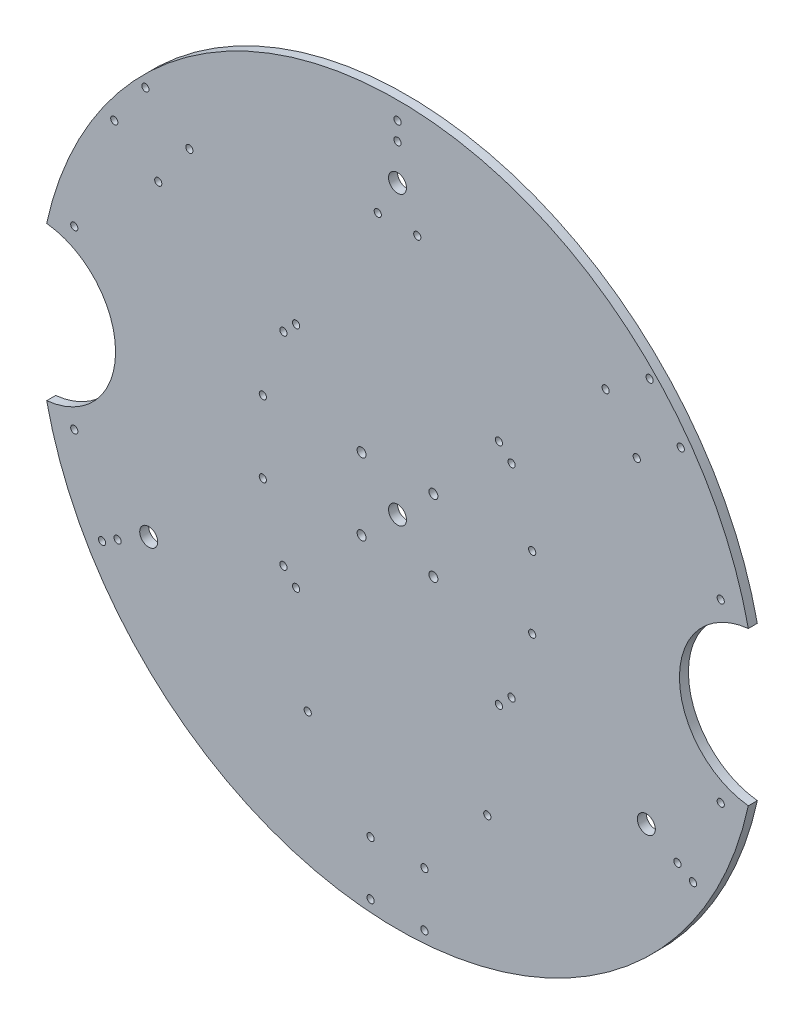
from build123d import *

# Parameters (mm, degrees)
SKETCH1_R           = 200
BOSS_EXTRUDE1_DEPTH = 5
SKETCH3_R           = 2
CUT_EXTRUDE1_DEPTH  = 5
CIRPATTERN1_COUNT   = 3
CUT_EXTRUDE2_REACH  = 7
SKETCH4_R           = 43
CUT_EXTRUDE3_REACH  = 7
SKETCH5_R           = 2
CUT_EXTRUDE4_REACH  = 7
SKETCH6_R           = 2.5
SKETCH6_R_2         = 5
CUT_EXTRUDE5_REACH  = 7
SKETCH7_R           = 2
CUT_EXTRUDE6_REACH  = 7
SKETCH8_R           = 2
CUT_EXTRUDE7_REACH  = 7
SKETCH9_R           = 2
CUT_EXTRUDE8_REACH  = 7
SKETCH11_R          = 2
CUT_EXTRUDE9_REACH  = 7
SKETCH12_R          = 2
CUT_EXTRUDE10_REACH = 7
SKETCH10_R          = 5


with BuildPart() as part:
    # Sketch1 → Boss-Extrude1 (new body)
    with BuildSketch(Plane.XY):
        Circle(SKETCH1_R)
    extrude(amount=BOSS_EXTRUDE1_DEPTH)

    # Sketch3 → Cut-Extrude1 (cut)
    with BuildSketch(Plane.XY.offset(5)):
        with Locations((0, 190)):
            Circle(SKETCH3_R)
        with Locations((0, 180)):
            Circle(SKETCH3_R)
    cut_extrude1 = extrude(amount=-CUT_EXTRUDE1_DEPTH, mode=Mode.SUBTRACT)

    # CirPattern1: Cut-Extrude1 ×3 about axis
    cirpattern1_axis = Axis((0, 0, 0), (0, 0, 1))
    for i in range(1, CIRPATTERN1_COUNT):
        add(cut_extrude1.rotate(cirpattern1_axis, i * 360 / CIRPATTERN1_COUNT), mode=Mode.SUBTRACT)

    # Sketch4 → Cut-Extrude2 (cut, up to next)
    with BuildSketch(Plane.XY.offset(5), mode=Mode.PRIVATE) as cut_extrude2_sk1:
        with Locations((-200, 0)):
            Circle(SKETCH4_R)
    cut_extrude2_tool1 = extrude(cut_extrude2_sk1.sketch, amount=-CUT_EXTRUDE2_REACH, mode=Mode.PRIVATE) & part.part
    add(cut_extrude2_tool1.solids().sort_by_distance((-200, 0, 5))[0], mode=Mode.SUBTRACT)
    # Sketch4 → Cut-Extrude2 (cut, up to next)
    with BuildSketch(Plane.XY.offset(5), mode=Mode.PRIVATE) as cut_extrude2_sk2:
        with Locations((200, 0)):
            Circle(SKETCH4_R)
    cut_extrude2_tool2 = extrude(cut_extrude2_sk2.sketch, amount=-CUT_EXTRUDE2_REACH, mode=Mode.PRIVATE) & part.part
    add(cut_extrude2_tool2.solids().sort_by_distance((200, 0, 5))[0], mode=Mode.SUBTRACT)

    # Sketch5 → Cut-Extrude3 (cut, up to next)
    with BuildSketch(Plane.XY.offset(5), mode=Mode.PRIVATE) as cut_extrude3_sk1:
        with Locations((180, 49)):
            Circle(SKETCH5_R)
    cut_extrude3_tool1 = extrude(cut_extrude3_sk1.sketch, amount=-CUT_EXTRUDE3_REACH, mode=Mode.PRIVATE) & part.part
    add(cut_extrude3_tool1.solids().sort_by_distance((180, 49, 5))[0], mode=Mode.SUBTRACT)
    # Sketch5 → Cut-Extrude3 (cut, up to next)
    with BuildSketch(Plane.XY.offset(5), mode=Mode.PRIVATE) as cut_extrude3_sk2:
        with Locations((180, -49)):
            Circle(SKETCH5_R)
    cut_extrude3_tool2 = extrude(cut_extrude3_sk2.sketch, amount=-CUT_EXTRUDE3_REACH, mode=Mode.PRIVATE) & part.part
    add(cut_extrude3_tool2.solids().sort_by_distance((180, -49, 5))[0], mode=Mode.SUBTRACT)
    # Sketch5 → Cut-Extrude3 (cut, up to next)
    with BuildSketch(Plane.XY.offset(5), mode=Mode.PRIVATE) as cut_extrude3_sk3:
        with Locations((-180, -49)):
            Circle(SKETCH5_R)
    cut_extrude3_tool3 = extrude(cut_extrude3_sk3.sketch, amount=-CUT_EXTRUDE3_REACH, mode=Mode.PRIVATE) & part.part
    add(cut_extrude3_tool3.solids().sort_by_distance((-180, -49, 5))[0], mode=Mode.SUBTRACT)
    # Sketch5 → Cut-Extrude3 (cut, up to next)
    with BuildSketch(Plane.XY.offset(5), mode=Mode.PRIVATE) as cut_extrude3_sk4:
        with Locations((-180, 49)):
            Circle(SKETCH5_R)
    cut_extrude3_tool4 = extrude(cut_extrude3_sk4.sketch, amount=-CUT_EXTRUDE3_REACH, mode=Mode.PRIVATE) & part.part
    add(cut_extrude3_tool4.solids().sort_by_distance((-180, 49, 5))[0], mode=Mode.SUBTRACT)

    # Sketch6 → Cut-Extrude4 (cut, up to next)
    with BuildSketch(Plane.XY.offset(5), mode=Mode.PRIVATE) as cut_extrude4_sk1:
        with Locations((-20, -20)):
            Circle(SKETCH6_R)
    cut_extrude4_tool1 = extrude(cut_extrude4_sk1.sketch, amount=-CUT_EXTRUDE4_REACH, mode=Mode.PRIVATE) & part.part
    add(cut_extrude4_tool1.solids().sort_by_distance((-20, -20, 5))[0], mode=Mode.SUBTRACT)
    # Sketch6 → Cut-Extrude4 (cut, up to next)
    with BuildSketch(Plane.XY.offset(5), mode=Mode.PRIVATE) as cut_extrude4_sk2:
        with Locations((-20, 20)):
            Circle(SKETCH6_R)
    cut_extrude4_tool2 = extrude(cut_extrude4_sk2.sketch, amount=-CUT_EXTRUDE4_REACH, mode=Mode.PRIVATE) & part.part
    add(cut_extrude4_tool2.solids().sort_by_distance((-20, 20, 5))[0], mode=Mode.SUBTRACT)
    # Sketch6 → Cut-Extrude4 (cut, up to next)
    with BuildSketch(Plane.XY.offset(5), mode=Mode.PRIVATE) as cut_extrude4_sk3:
        Circle(SKETCH6_R_2)
    cut_extrude4_tool3 = extrude(cut_extrude4_sk3.sketch, amount=-CUT_EXTRUDE4_REACH, mode=Mode.PRIVATE) & part.part
    add(cut_extrude4_tool3.solids().sort_by_distance((0, 0, 5))[0], mode=Mode.SUBTRACT)
    # Sketch6 → Cut-Extrude4 (cut, up to next)
    with BuildSketch(Plane.XY.offset(5), mode=Mode.PRIVATE) as cut_extrude4_sk4:
        with Locations((20, -20)):
            Circle(SKETCH6_R)
    cut_extrude4_tool4 = extrude(cut_extrude4_sk4.sketch, amount=-CUT_EXTRUDE4_REACH, mode=Mode.PRIVATE) & part.part
    add(cut_extrude4_tool4.solids().sort_by_distance((20, -20, 5))[0], mode=Mode.SUBTRACT)
    # Sketch6 → Cut-Extrude4 (cut, up to next)
    with BuildSketch(Plane.XY.offset(5), mode=Mode.PRIVATE) as cut_extrude4_sk5:
        with Locations((20, 20)):
            Circle(SKETCH6_R)
    cut_extrude4_tool5 = extrude(cut_extrude4_sk5.sketch, amount=-CUT_EXTRUDE4_REACH, mode=Mode.PRIVATE) & part.part
    add(cut_extrude4_tool5.solids().sort_by_distance((20, 20, 5))[0], mode=Mode.SUBTRACT)

    # Sketch7 → Cut-Extrude5 (cut, up to next)
    with BuildSketch(Plane.XY.offset(5), mode=Mode.PRIVATE) as cut_extrude5_sk1:
        with Locations((-15, -193)):
            Circle(SKETCH7_R)
    cut_extrude5_tool1 = extrude(cut_extrude5_sk1.sketch, amount=-CUT_EXTRUDE5_REACH, mode=Mode.PRIVATE) & part.part
    add(cut_extrude5_tool1.solids().sort_by_distance((-15, -193, 5))[0], mode=Mode.SUBTRACT)
    # Sketch7 → Cut-Extrude5 (cut, up to next)
    with BuildSketch(Plane.XY.offset(5), mode=Mode.PRIVATE) as cut_extrude5_sk2:
        with Locations((15, -193)):
            Circle(SKETCH7_R)
    cut_extrude5_tool2 = extrude(cut_extrude5_sk2.sketch, amount=-CUT_EXTRUDE5_REACH, mode=Mode.PRIVATE) & part.part
    add(cut_extrude5_tool2.solids().sort_by_distance((15, -193, 5))[0], mode=Mode.SUBTRACT)
    # Sketch7 → Cut-Extrude5 (cut, up to next)
    with BuildSketch(Plane.XY.offset(5), mode=Mode.PRIVATE) as cut_extrude5_sk3:
        with Locations((15, -163)):
            Circle(SKETCH7_R)
    cut_extrude5_tool3 = extrude(cut_extrude5_sk3.sketch, amount=-CUT_EXTRUDE5_REACH, mode=Mode.PRIVATE) & part.part
    add(cut_extrude5_tool3.solids().sort_by_distance((15, -163, 5))[0], mode=Mode.SUBTRACT)
    # Sketch7 → Cut-Extrude5 (cut, up to next)
    with BuildSketch(Plane.XY.offset(5), mode=Mode.PRIVATE) as cut_extrude5_sk4:
        with Locations((-15, -163)):
            Circle(SKETCH7_R)
    cut_extrude5_tool4 = extrude(cut_extrude5_sk4.sketch, amount=-CUT_EXTRUDE5_REACH, mode=Mode.PRIVATE) & part.part
    add(cut_extrude5_tool4.solids().sort_by_distance((-15, -163, 5))[0], mode=Mode.SUBTRACT)
    # Sketch7 → Cut-Extrude5 (cut, up to next)
    with BuildSketch(Plane.XY.offset(5), mode=Mode.PRIVATE) as cut_extrude5_sk5:
        with Locations((133.235060167, 93.901419803)):
            Circle(SKETCH7_R)
    cut_extrude5_tool5 = extrude(cut_extrude5_sk5.sketch, amount=-CUT_EXTRUDE5_REACH, mode=Mode.PRIVATE) & part.part
    add(cut_extrude5_tool5.solids().sort_by_distance((133.23506, 93.90142, 5))[0], mode=Mode.SUBTRACT)
    # Sketch7 → Cut-Extrude5 (cut, up to next)
    with BuildSketch(Plane.XY.offset(5), mode=Mode.PRIVATE) as cut_extrude5_sk6:
        with Locations((115.916428804, 118.39764416)):
            Circle(SKETCH7_R)
    cut_extrude5_tool6 = extrude(cut_extrude5_sk6.sketch, amount=-CUT_EXTRUDE5_REACH, mode=Mode.PRIVATE) & part.part
    add(cut_extrude5_tool6.solids().sort_by_distance((115.916429, 118.397644, 5))[0], mode=Mode.SUBTRACT)
    # Sketch7 → Cut-Extrude5 (cut, up to next)
    with BuildSketch(Plane.XY.offset(5), mode=Mode.PRIVATE) as cut_extrude5_sk7:
        with Locations((140.412653161, 135.716275522)):
            Circle(SKETCH7_R)
    cut_extrude5_tool7 = extrude(cut_extrude5_sk7.sketch, amount=-CUT_EXTRUDE5_REACH, mode=Mode.PRIVATE) & part.part
    add(cut_extrude5_tool7.solids().sort_by_distance((140.412653, 135.716276, 5))[0], mode=Mode.SUBTRACT)
    # Sketch7 → Cut-Extrude5 (cut, up to next)
    with BuildSketch(Plane.XY.offset(5), mode=Mode.PRIVATE) as cut_extrude5_sk8:
        with Locations((157.731284523, 111.220051166)):
            Circle(SKETCH7_R)
    cut_extrude5_tool8 = extrude(cut_extrude5_sk8.sketch, amount=-CUT_EXTRUDE5_REACH, mode=Mode.PRIVATE) & part.part
    add(cut_extrude5_tool8.solids().sort_by_distance((157.731285, 111.220051, 5))[0], mode=Mode.SUBTRACT)
    # Sketch7 → Cut-Extrude5 (cut, up to next)
    with BuildSketch(Plane.XY.offset(5), mode=Mode.PRIVATE) as cut_extrude5_sk9:
        with Locations((-157.731284523, 111.220051166)):
            Circle(SKETCH7_R)
    cut_extrude5_tool9 = extrude(cut_extrude5_sk9.sketch, amount=-CUT_EXTRUDE5_REACH, mode=Mode.PRIVATE) & part.part
    add(cut_extrude5_tool9.solids().sort_by_distance((-157.731285, 111.220051, 5))[0], mode=Mode.SUBTRACT)
    # Sketch7 → Cut-Extrude5 (cut, up to next)
    with BuildSketch(Plane.XY.offset(5), mode=Mode.PRIVATE) as cut_extrude5_sk10:
        with Locations((-133.235060167, 93.901419803)):
            Circle(SKETCH7_R)
    cut_extrude5_tool10 = extrude(cut_extrude5_sk10.sketch, amount=-CUT_EXTRUDE5_REACH, mode=Mode.PRIVATE) & part.part
    add(cut_extrude5_tool10.solids().sort_by_distance((-133.23506, 93.90142, 5))[0], mode=Mode.SUBTRACT)
    # Sketch7 → Cut-Extrude5 (cut, up to next)
    with BuildSketch(Plane.XY.offset(5), mode=Mode.PRIVATE) as cut_extrude5_sk11:
        with Locations((-115.916428804, 118.39764416)):
            Circle(SKETCH7_R)
    cut_extrude5_tool11 = extrude(cut_extrude5_sk11.sketch, amount=-CUT_EXTRUDE5_REACH, mode=Mode.PRIVATE) & part.part
    add(cut_extrude5_tool11.solids().sort_by_distance((-115.916429, 118.397644, 5))[0], mode=Mode.SUBTRACT)
    # Sketch7 → Cut-Extrude5 (cut, up to next)
    with BuildSketch(Plane.XY.offset(5), mode=Mode.PRIVATE) as cut_extrude5_sk12:
        with Locations((-140.412653161, 135.716275522)):
            Circle(SKETCH7_R)
    cut_extrude5_tool12 = extrude(cut_extrude5_sk12.sketch, amount=-CUT_EXTRUDE5_REACH, mode=Mode.PRIVATE) & part.part
    add(cut_extrude5_tool12.solids().sort_by_distance((-140.412653, 135.716276, 5))[0], mode=Mode.SUBTRACT)

    # Sketch8 → Cut-Extrude6 (cut, up to next)
    with BuildSketch(Plane.XY.offset(5), mode=Mode.PRIVATE) as cut_extrude6_sk1:
        with Locations((-11, 140)):
            Circle(SKETCH8_R)
    cut_extrude6_tool1 = extrude(cut_extrude6_sk1.sketch, amount=-CUT_EXTRUDE6_REACH, mode=Mode.PRIVATE) & part.part
    add(cut_extrude6_tool1.solids().sort_by_distance((-11, 140, 5))[0], mode=Mode.SUBTRACT)
    # Sketch8 → Cut-Extrude6 (cut, up to next)
    with BuildSketch(Plane.XY.offset(5), mode=Mode.PRIVATE) as cut_extrude6_sk2:
        with Locations((11, 140)):
            Circle(SKETCH8_R)
    cut_extrude6_tool2 = extrude(cut_extrude6_sk2.sketch, amount=-CUT_EXTRUDE6_REACH, mode=Mode.PRIVATE) & part.part
    add(cut_extrude6_tool2.solids().sort_by_distance((11, 140, 5))[0], mode=Mode.SUBTRACT)

    # Sketch9 → Cut-Extrude7 (cut, up to next)
    with BuildSketch(Plane.XY.offset(5), mode=Mode.PRIVATE) as cut_extrude7_sk1:
        with Locations((75, -20)):
            Circle(SKETCH9_R)
    cut_extrude7_tool1 = extrude(cut_extrude7_sk1.sketch, amount=-CUT_EXTRUDE7_REACH, mode=Mode.PRIVATE) & part.part
    add(cut_extrude7_tool1.solids().sort_by_distance((75, -20, 5))[0], mode=Mode.SUBTRACT)
    # Sketch9 → Cut-Extrude7 (cut, up to next)
    with BuildSketch(Plane.XY.offset(5), mode=Mode.PRIVATE) as cut_extrude7_sk2:
        with Locations((75, 20)):
            Circle(SKETCH9_R)
    cut_extrude7_tool2 = extrude(cut_extrude7_sk2.sketch, amount=-CUT_EXTRUDE7_REACH, mode=Mode.PRIVATE) & part.part
    add(cut_extrude7_tool2.solids().sort_by_distance((75, 20, 5))[0], mode=Mode.SUBTRACT)
    # Sketch9 → Cut-Extrude7 (cut, up to next)
    with BuildSketch(Plane.XY.offset(5), mode=Mode.PRIVATE) as cut_extrude7_sk3:
        with Locations((-75, -20)):
            Circle(SKETCH9_R)
    cut_extrude7_tool3 = extrude(cut_extrude7_sk3.sketch, amount=-CUT_EXTRUDE7_REACH, mode=Mode.PRIVATE) & part.part
    add(cut_extrude7_tool3.solids().sort_by_distance((-75, -20, 5))[0], mode=Mode.SUBTRACT)
    # Sketch9 → Cut-Extrude7 (cut, up to next)
    with BuildSketch(Plane.XY.offset(5), mode=Mode.PRIVATE) as cut_extrude7_sk4:
        with Locations((-75, 20)):
            Circle(SKETCH9_R)
    cut_extrude7_tool4 = extrude(cut_extrude7_sk4.sketch, amount=-CUT_EXTRUDE7_REACH, mode=Mode.PRIVATE) & part.part
    add(cut_extrude7_tool4.solids().sort_by_distance((-75, 20, 5))[0], mode=Mode.SUBTRACT)

    # Sketch11 → Cut-Extrude8 (cut, up to next)
    with BuildSketch(Plane(origin=(0, 0, 0), x_dir=(-1, 0, 0), z_dir=(0, 0, -1)), mode=Mode.PRIVATE) as cut_extrude8_sk1:
        with Locations((-50, -120)):
            Circle(SKETCH11_R)
    cut_extrude8_tool1 = extrude(cut_extrude8_sk1.sketch, amount=-CUT_EXTRUDE8_REACH, mode=Mode.PRIVATE) & part.part
    add(cut_extrude8_tool1.solids().sort_by_distance((50, -120, 0))[0], mode=Mode.SUBTRACT)
    # Sketch11 → Cut-Extrude8 (cut, up to next)
    with BuildSketch(Plane(origin=(0, 0, 0), x_dir=(-1, 0, 0), z_dir=(0, 0, -1)), mode=Mode.PRIVATE) as cut_extrude8_sk2:
        with Locations((50, -120)):
            Circle(SKETCH11_R)
    cut_extrude8_tool2 = extrude(cut_extrude8_sk2.sketch, amount=-CUT_EXTRUDE8_REACH, mode=Mode.PRIVATE) & part.part
    add(cut_extrude8_tool2.solids().sort_by_distance((-50, -120, 0))[0], mode=Mode.SUBTRACT)

    # Sketch12 → Cut-Extrude9 (cut, up to next)
    with BuildSketch(Plane(origin=(0, 0, 0), x_dir=(-1, 0, 0), z_dir=(0, 0, -1)), mode=Mode.PRIVATE) as cut_extrude9_sk1:
        with Locations((-63.535533906, -56.464466094)):
            Circle(SKETCH12_R)
    cut_extrude9_tool1 = extrude(cut_extrude9_sk1.sketch, amount=-CUT_EXTRUDE9_REACH, mode=Mode.PRIVATE) & part.part
    add(cut_extrude9_tool1.solids().sort_by_distance((63.535534, -56.464466, 0))[0], mode=Mode.SUBTRACT)
    # Sketch12 → Cut-Extrude9 (cut, up to next)
    with BuildSketch(Plane(origin=(0, 0, 0), x_dir=(-1, 0, 0), z_dir=(0, 0, -1)), mode=Mode.PRIVATE) as cut_extrude9_sk2:
        with Locations((-56.464466094, -63.535533906)):
            Circle(SKETCH12_R)
    cut_extrude9_tool2 = extrude(cut_extrude9_sk2.sketch, amount=-CUT_EXTRUDE9_REACH, mode=Mode.PRIVATE) & part.part
    add(cut_extrude9_tool2.solids().sort_by_distance((56.464466, -63.535534, 0))[0], mode=Mode.SUBTRACT)
    # Sketch12 → Cut-Extrude9 (cut, up to next)
    with BuildSketch(Plane(origin=(0, 0, 0), x_dir=(-1, 0, 0), z_dir=(0, 0, -1)), mode=Mode.PRIVATE) as cut_extrude9_sk3:
        with Locations((63.535533906, -56.464466094)):
            Circle(SKETCH12_R)
    cut_extrude9_tool3 = extrude(cut_extrude9_sk3.sketch, amount=-CUT_EXTRUDE9_REACH, mode=Mode.PRIVATE) & part.part
    add(cut_extrude9_tool3.solids().sort_by_distance((-63.535534, -56.464466, 0))[0], mode=Mode.SUBTRACT)
    # Sketch12 → Cut-Extrude9 (cut, up to next)
    with BuildSketch(Plane(origin=(0, 0, 0), x_dir=(-1, 0, 0), z_dir=(0, 0, -1)), mode=Mode.PRIVATE) as cut_extrude9_sk4:
        with Locations((56.464466094, -63.535533906)):
            Circle(SKETCH12_R)
    cut_extrude9_tool4 = extrude(cut_extrude9_sk4.sketch, amount=-CUT_EXTRUDE9_REACH, mode=Mode.PRIVATE) & part.part
    add(cut_extrude9_tool4.solids().sort_by_distance((-56.464466, -63.535534, 0))[0], mode=Mode.SUBTRACT)
    # Sketch12 → Cut-Extrude9 (cut, up to next)
    with BuildSketch(Plane(origin=(0, 0, 0), x_dir=(-1, 0, 0), z_dir=(0, 0, -1)), mode=Mode.PRIVATE) as cut_extrude9_sk5:
        with Locations((63.535533906, 56.464466094)):
            Circle(SKETCH12_R)
    cut_extrude9_tool5 = extrude(cut_extrude9_sk5.sketch, amount=-CUT_EXTRUDE9_REACH, mode=Mode.PRIVATE) & part.part
    add(cut_extrude9_tool5.solids().sort_by_distance((-63.535534, 56.464466, 0))[0], mode=Mode.SUBTRACT)
    # Sketch12 → Cut-Extrude9 (cut, up to next)
    with BuildSketch(Plane(origin=(0, 0, 0), x_dir=(-1, 0, 0), z_dir=(0, 0, -1)), mode=Mode.PRIVATE) as cut_extrude9_sk6:
        with Locations((56.464466094, 63.535533906)):
            Circle(SKETCH12_R)
    cut_extrude9_tool6 = extrude(cut_extrude9_sk6.sketch, amount=-CUT_EXTRUDE9_REACH, mode=Mode.PRIVATE) & part.part
    add(cut_extrude9_tool6.solids().sort_by_distance((-56.464466, 63.535534, 0))[0], mode=Mode.SUBTRACT)
    # Sketch12 → Cut-Extrude9 (cut, up to next)
    with BuildSketch(Plane(origin=(0, 0, 0), x_dir=(-1, 0, 0), z_dir=(0, 0, -1)), mode=Mode.PRIVATE) as cut_extrude9_sk7:
        with Locations((-56.464466094, 63.535533906)):
            Circle(SKETCH12_R)
    cut_extrude9_tool7 = extrude(cut_extrude9_sk7.sketch, amount=-CUT_EXTRUDE9_REACH, mode=Mode.PRIVATE) & part.part
    add(cut_extrude9_tool7.solids().sort_by_distance((56.464466, 63.535534, 0))[0], mode=Mode.SUBTRACT)
    # Sketch12 → Cut-Extrude9 (cut, up to next)
    with BuildSketch(Plane(origin=(0, 0, 0), x_dir=(-1, 0, 0), z_dir=(0, 0, -1)), mode=Mode.PRIVATE) as cut_extrude9_sk8:
        with Locations((-63.535533906, 56.464466094)):
            Circle(SKETCH12_R)
    cut_extrude9_tool8 = extrude(cut_extrude9_sk8.sketch, amount=-CUT_EXTRUDE9_REACH, mode=Mode.PRIVATE) & part.part
    add(cut_extrude9_tool8.solids().sort_by_distance((63.535534, 56.464466, 0))[0], mode=Mode.SUBTRACT)

    # Sketch10 → Cut-Extrude10 (cut, up to next)
    with BuildSketch(Plane(origin=(0, 0, 0), x_dir=(-1, 0, 0), z_dir=(0, 0, -1)), mode=Mode.PRIVATE) as cut_extrude10_sk1:
        with Locations((-138.564064606, -80)):
            Circle(SKETCH10_R)
    cut_extrude10_tool1 = extrude(cut_extrude10_sk1.sketch, amount=-CUT_EXTRUDE10_REACH, mode=Mode.PRIVATE) & part.part
    add(cut_extrude10_tool1.solids().sort_by_distance((138.564065, -80, 0))[0], mode=Mode.SUBTRACT)
    # Sketch10 → Cut-Extrude10 (cut, up to next)
    with BuildSketch(Plane(origin=(0, 0, 0), x_dir=(-1, 0, 0), z_dir=(0, 0, -1)), mode=Mode.PRIVATE) as cut_extrude10_sk2:
        with Locations((138.564064606, -80)):
            Circle(SKETCH10_R)
    cut_extrude10_tool2 = extrude(cut_extrude10_sk2.sketch, amount=-CUT_EXTRUDE10_REACH, mode=Mode.PRIVATE) & part.part
    add(cut_extrude10_tool2.solids().sort_by_distance((-138.564065, -80, 0))[0], mode=Mode.SUBTRACT)
    # Sketch10 → Cut-Extrude10 (cut, up to next)
    with BuildSketch(Plane(origin=(0, 0, 0), x_dir=(-1, 0, 0), z_dir=(0, 0, -1)), mode=Mode.PRIVATE) as cut_extrude10_sk3:
        with Locations((0, 160)):
            Circle(SKETCH10_R)
    cut_extrude10_tool3 = extrude(cut_extrude10_sk3.sketch, amount=-CUT_EXTRUDE10_REACH, mode=Mode.PRIVATE) & part.part
    add(cut_extrude10_tool3.solids().sort_by_distance((0, 160, 0))[0], mode=Mode.SUBTRACT)


solid = part.part
